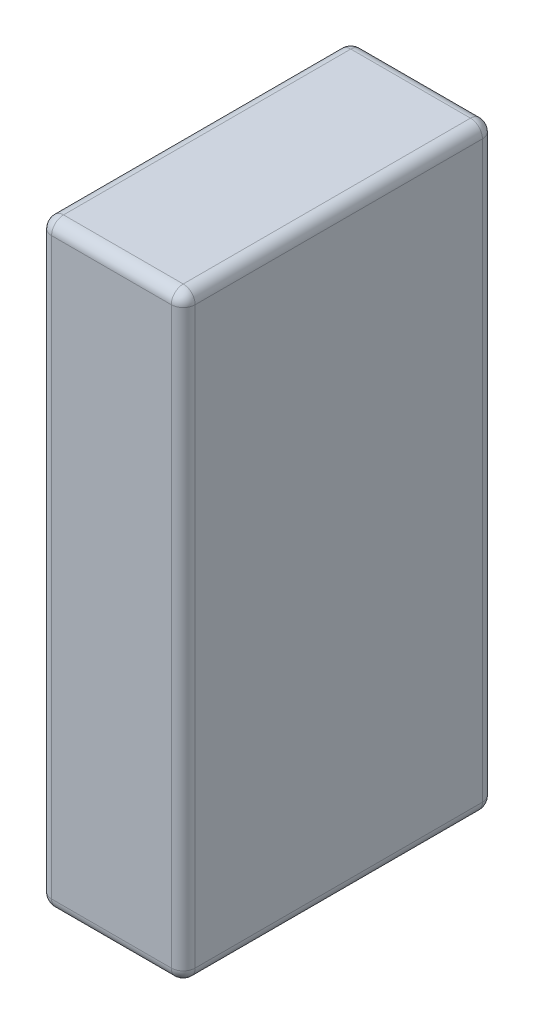
from build123d import *

# Parameters (mm, degrees)
ESBO_O1_W                = 120
ESBO_O1_H                = 260
RESSALTO_EXTRUS_O1_DEPTH = 500
FILETE1_R                = 10


with BuildPart() as part:
    # Esboço1 → Ressalto-extrusão1 (new body)
    with BuildSketch(Plane(origin=(0, 0, 0), x_dir=(1, 0, 0), z_dir=(0, 1, 0))):
        Rectangle(ESBO_O1_W, ESBO_O1_H)
    extrude(amount=RESSALTO_EXTRUS_O1_DEPTH)

    # Filete1
    filete1_edges = [part.edges().sort_by_distance(p)[0] for p in [
        (-60, 500, 0),
        (0, 500, 130),
        (60, 500, 0),
        (0, 0, 130),
        (-60, 0, 0),
        (0, 0, -130),
        (60, 0, 0),
        (60, 250, 130),
        (-60, 250, 130),
        (-60, 250, -130),
        (60, 250, -130),
        (0, 500, -130),
    ]]
    fillet(filete1_edges, radius=FILETE1_R)


solid = part.part
